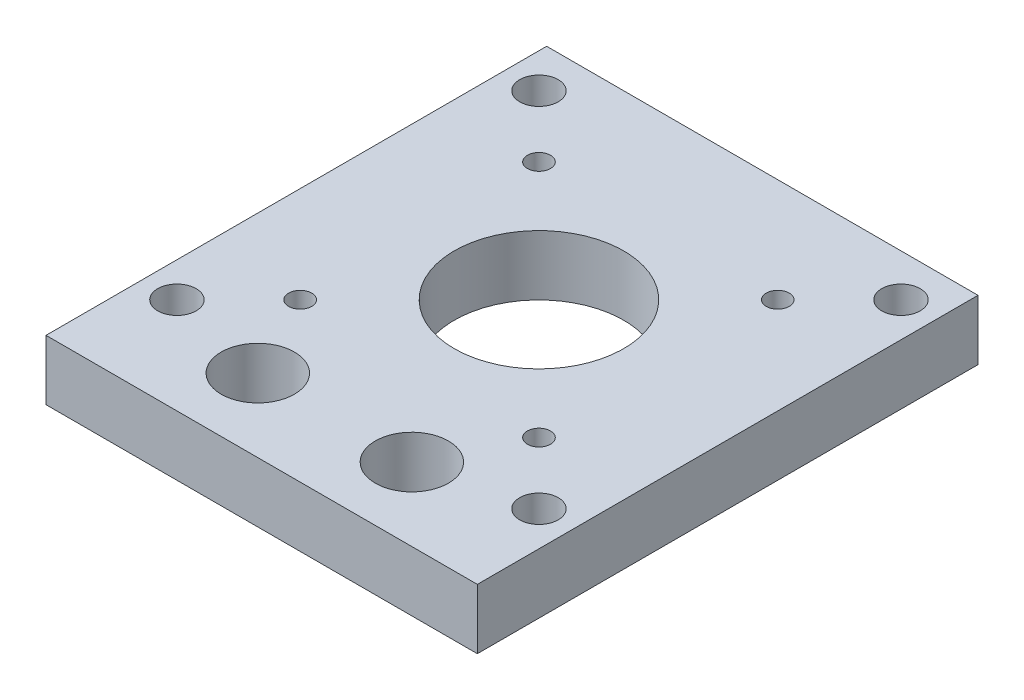
from build123d import *

# Parameters (mm, degrees)
SKETCH_1_W          = 56
SKETCH_1_H          = 65
EXTRUDE_1_DEPTH     = 7.8
SKETCH_3_R          = 4.75
CUT_EXTRUDE_2_DEPTH = 8.8
SKETCH_4_R          = 11
SKETCH_4_R_2        = 1.5
SKETCH_4_R_3        = 2.5
CUT_EXTRUDE_3_DEPTH = 8.8


with BuildPart() as part:
    # 草图1 → 凸台-拉伸1 (new body)
    with BuildSketch(Plane(origin=(0, 0, 0), x_dir=(1, 0, 0), z_dir=(0, 1, 0))):
        Rectangle(SKETCH_1_W, SKETCH_1_H)
    extrude(amount=EXTRUDE_1_DEPTH)

    # 草图3 → 切除-拉伸2 (cut, through all)
    with BuildSketch(Plane(origin=(0, 7.8, 0), x_dir=(1, 0, 0), z_dir=(0, 1, 0))):
        with Locations((-10, -23)):
            Circle(SKETCH_3_R)
        with Locations((10, -23)):
            Circle(SKETCH_3_R)
    extrude(amount=-CUT_EXTRUDE_2_DEPTH, mode=Mode.SUBTRACT)

    # 草图4 → 切除-拉伸3 (cut, through all)
    with BuildSketch(Plane(origin=(0, 7.8, 0), x_dir=(1, 0, 0), z_dir=(0, 1, 0))):
        with Locations((0, 3.5)):
            Circle(SKETCH_4_R)
        with Locations((-15.5, 19)):
            Circle(SKETCH_4_R_2)
        with Locations((15.5, 19)):
            Circle(SKETCH_4_R_2)
        with Locations((15.5, -12)):
            Circle(SKETCH_4_R_2)
        with Locations((-15.5, -12)):
            Circle(SKETCH_4_R_2)
        with Locations((-23.5, 27)):
            Circle(SKETCH_4_R_3)
        with Locations((23.5, 27)):
            Circle(SKETCH_4_R_3)
        with Locations((23.5, -20)):
            Circle(SKETCH_4_R_3)
        with Locations((-23.5, -20)):
            Circle(SKETCH_4_R_3)
    extrude(amount=-CUT_EXTRUDE_3_DEPTH, mode=Mode.SUBTRACT)


solid = part.part
